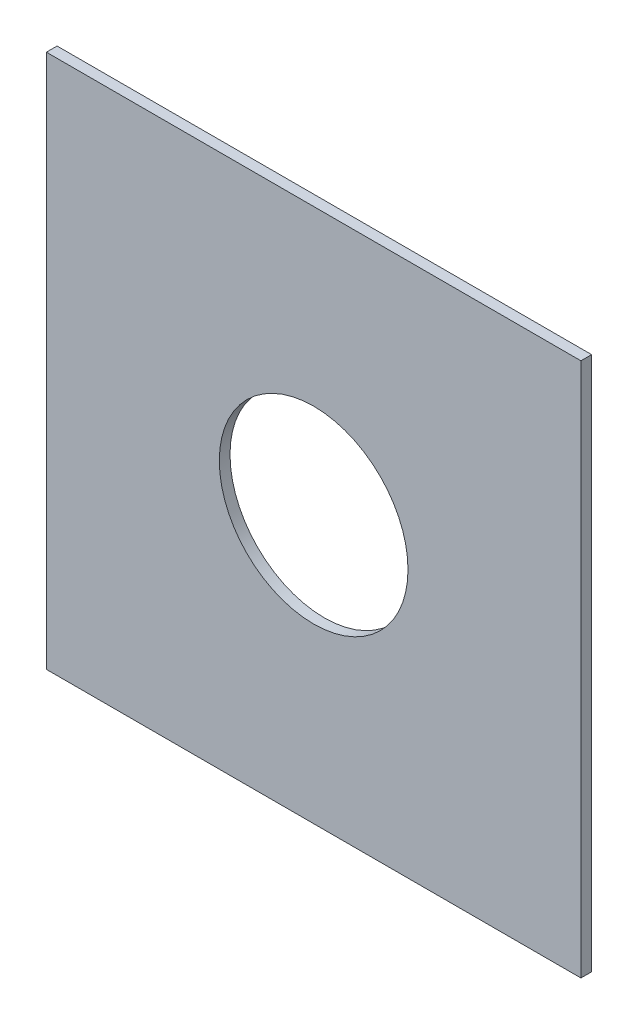
from build123d import *

# Parameters (mm, degrees)
SKETCH1_W           = 500
SKETCH1_H           = 500
SKETCH1_R           = 88.25
BOSS_EXTRUDE1_DEPTH = 10


with BuildPart() as part:
    # Sketch1 → Boss-Extrude1 (new body)
    with BuildSketch(Plane.XY):
        Rectangle(SKETCH1_W, SKETCH1_H)
        Circle(SKETCH1_R, mode=Mode.SUBTRACT)
    extrude(amount=BOSS_EXTRUDE1_DEPTH)


solid = part.part
